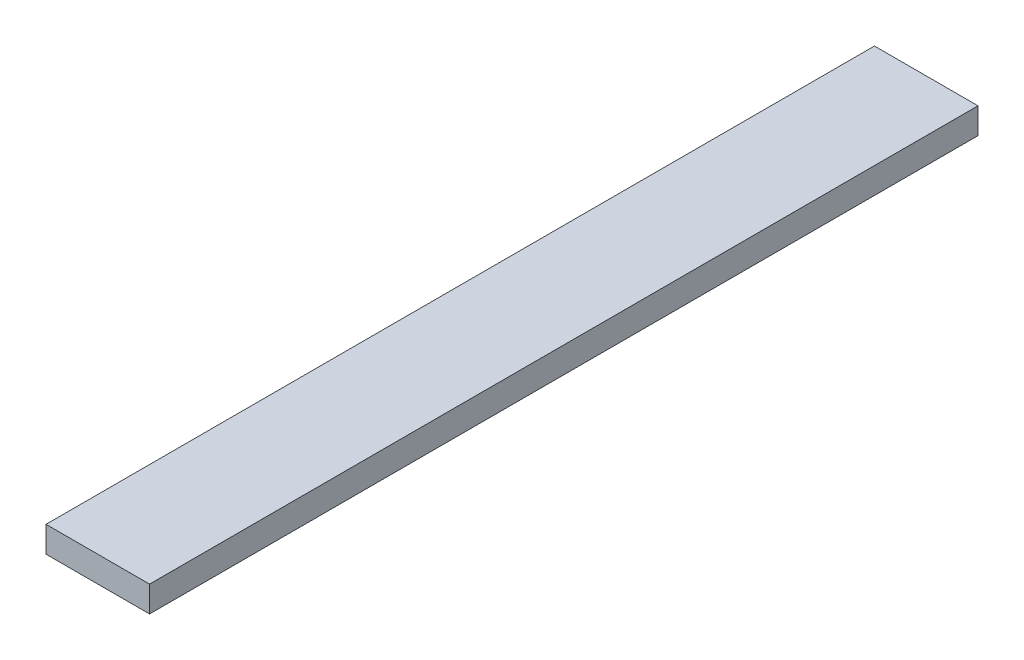
from build123d import *

# Parameters (mm, degrees)
SKETCH1_W           = 76.2
SKETCH1_H           = 609.6
BOSS_EXTRUDE1_DEPTH = 19.05


with BuildPart() as part:
    # Sketch1 → Boss-Extrude1 (new body)
    with BuildSketch(Plane(origin=(0, 0, 0), x_dir=(1, 0, 0), z_dir=(0, 1, 0))):
        Rectangle(SKETCH1_W, SKETCH1_H)
    extrude(amount=BOSS_EXTRUDE1_DEPTH)


solid = part.part
